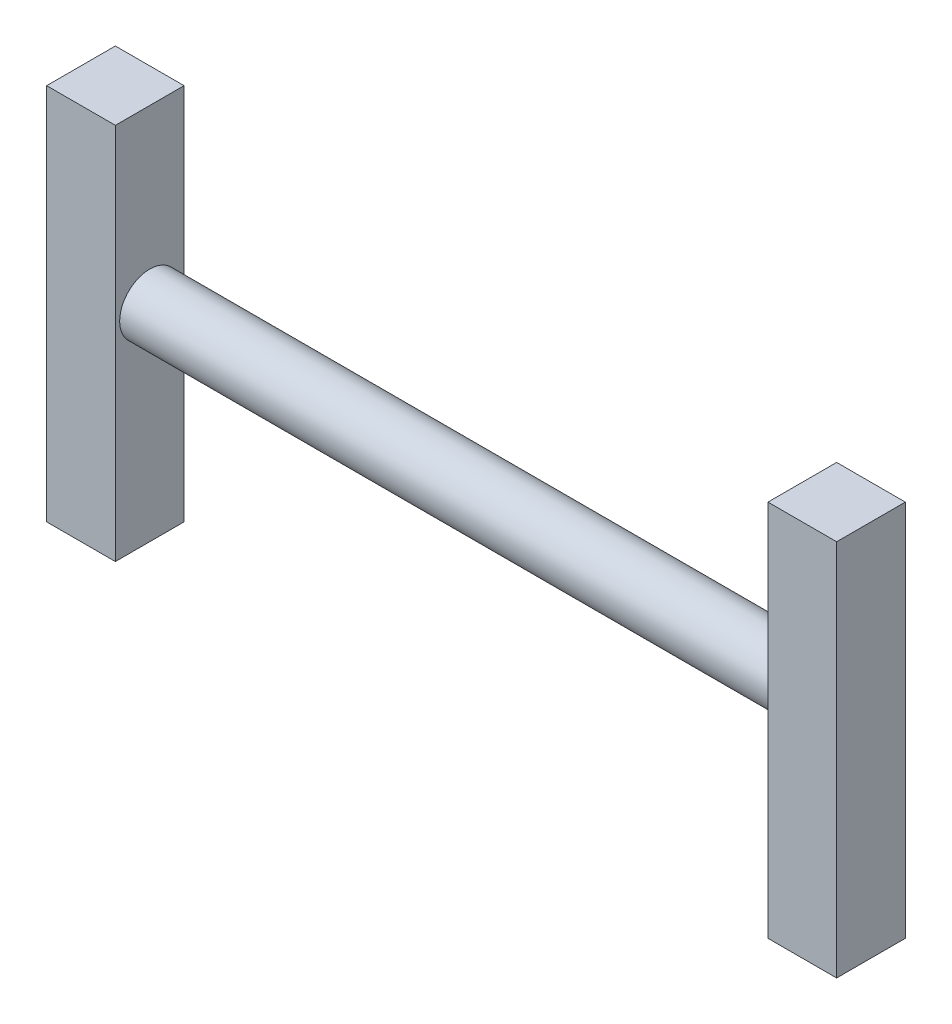
from build123d import *

# Parameters (mm, degrees)
SKETCH1_W           = 40
SKETCH1_H           = 40
BOSS_EXTRUDE1_DEPTH = 110
SKETCH2_R           = 17.5
BOSS_EXTRUDE2_DEPTH = 210


with BuildPart() as part:
    # Sketch1 → Boss-Extrude1 (new body, symmetric)
    with BuildSketch(Plane(origin=(0, 0, 0), x_dir=(1, 0, 0), z_dir=(0, 1, 0))):
        Rectangle(SKETCH1_W, SKETCH1_H)
    extrude(amount=BOSS_EXTRUDE1_DEPTH, both=True)

    # Sketch2 → Boss-Extrude2 (add)
    with BuildSketch(Plane(origin=(0, 0, 0), x_dir=(0, 0, -1), z_dir=(1, 0, 0))):
        with Locations((0, 10)):
            Circle(SKETCH2_R)
    extrude(amount=BOSS_EXTRUDE2_DEPTH)

    # Mirror7: part across plane


with BuildPart() as part_1:
    add(part.part)
    add(part.part.mirror(Plane(origin=(210, 10, 0), x_dir=(0, 0, 1), z_dir=(1, 0, 0))))


solid = part_1.part
